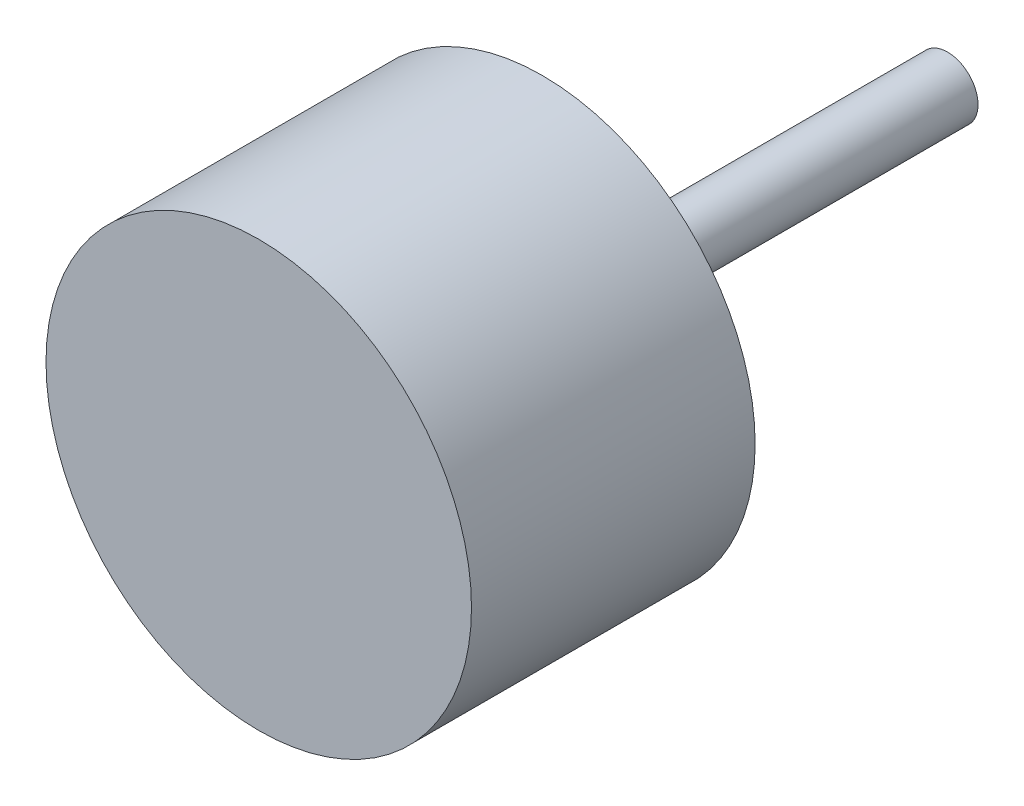
from build123d import *

# Parameters (mm, degrees)
ESQUISSE1_R        = 10.5
BOSS_EXTRU_1_DEPTH = 14
ESQUISSE2_R        = 1.5
BOSS_EXTRU_2_DEPTH = 20


with BuildPart() as part:
    # Esquisse1 → Boss.-Extru.1 (new body)
    with BuildSketch(Plane.XY):
        Circle(ESQUISSE1_R)
    extrude(amount=BOSS_EXTRU_1_DEPTH)

    # Esquisse2 → Boss.-Extru.2 (add)
    with BuildSketch(Plane(origin=(0, 0, 0), x_dir=(-1, 0, 0), z_dir=(0, 0, -1))):
        Circle(ESQUISSE2_R)
    extrude(amount=BOSS_EXTRU_2_DEPTH)


solid = part.part
